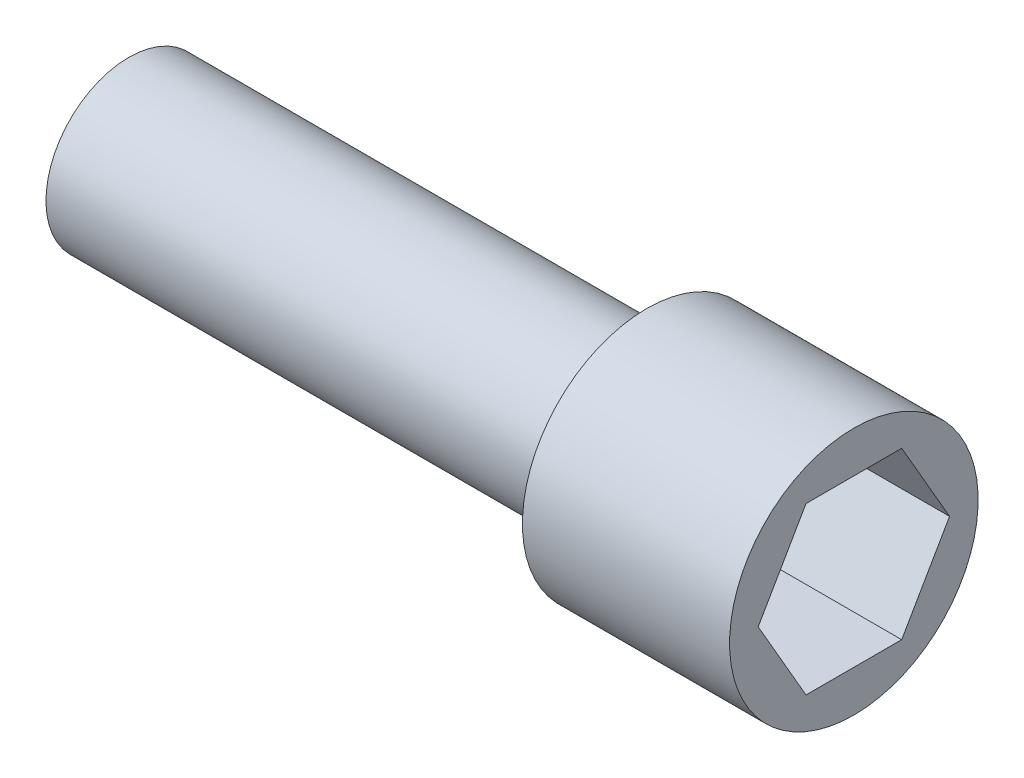
from build123d import *

# Parameters (mm, degrees)
CUT_EXTRUDE1_DEPTH = 7


with BuildPart() as part:
    # Sketch1 → Revolve1 (revolve)
    with BuildSketch(Plane.XY):
        Polygon((10, 0), (-25, 0), (-25, 4), (0, 4), (0, 6), (10, 6), align=None)
    revolve(axis=Axis((10, 0, 0), (-1, 0, 0)))

    # Sketch2 → Cut-Extrude1 (cut)
    with BuildSketch(Plane(origin=(10, 0, 0), x_dir=(0, 0, -1), z_dir=(1, 0, 0))):
        Polygon((4.618802154, 0), (2.309401077, 4), (-2.309401077, 4), (-4.618802154, 0), (-2.309401077, -4), (2.309401077, -4), align=None)
    extrude(amount=-CUT_EXTRUDE1_DEPTH, mode=Mode.SUBTRACT)


solid = part.part
